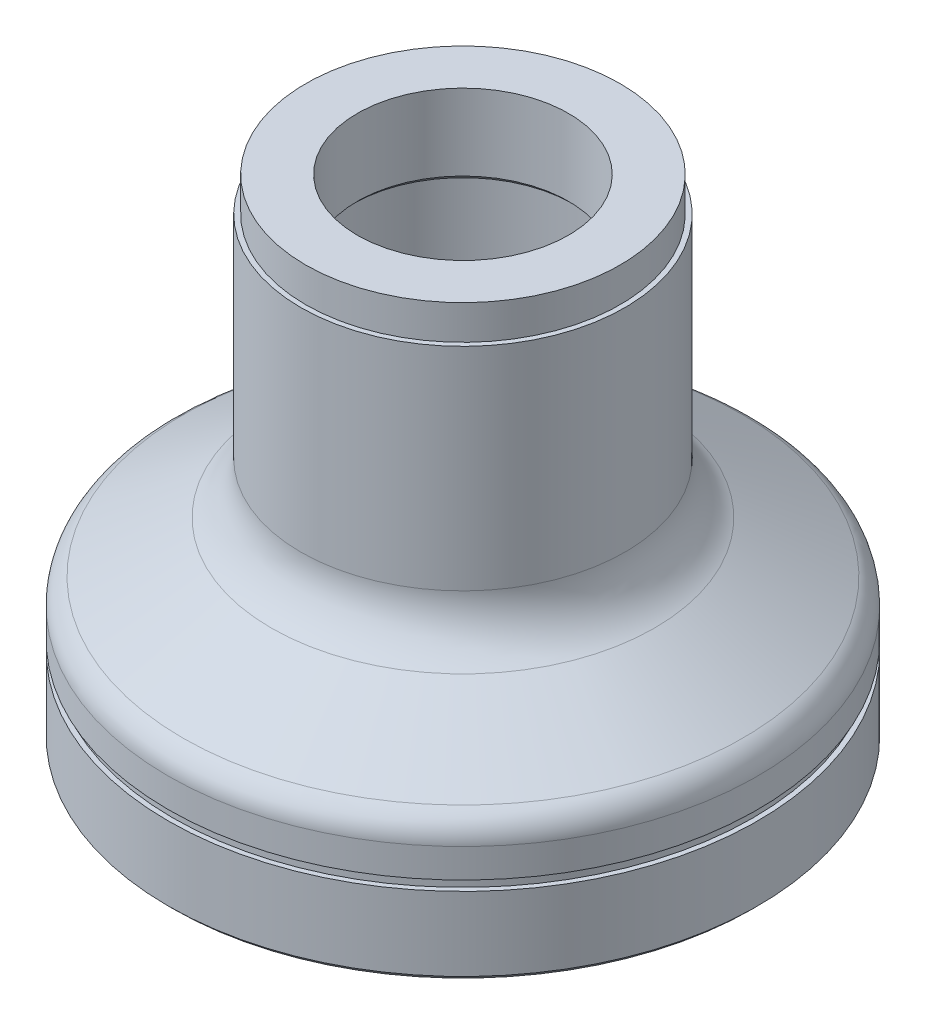
from build123d import *


with BuildPart() as part:
    # Esquisse1 → Révolution1 (revolve)
    with BuildSketch(Plane.XY, mode=Mode.PRIVATE) as r_volution1_sk:
        with BuildLine():
            Line((33, 94.535053287), (33, 51.422205102))
            ThreePointArc((33, 51.422205102), (34.607695155, 45.422205102), (39, 41.029900256))
            Line((39, 41.029900256), (57, 30.637595411))
            ThreePointArc((57, 30.637595411), (59.196152423, 28.441442988), (60, 25.441442988))
            Line((60, 25.441442988), (60, 19.535053287))
            Line((60, 19.535053287), (59, 19.535053287))
            Line((59, 19.535053287), (59, 17.535053287))
            Line((59, 17.535053287), (60, 17.535053287))
            Line((60, 17.535053287), (60, 2.535053287))
            Line((60, 2.535053287), (59, 1.535053287))
            Line((59, 1.535053287), (57, 1.535053287))
            Line((57, 1.535053287), (57, 6.535053287))
            Line((57, 6.535053287), (49, 6.535053287))
            Line((49, 6.535053287), (49, 24.535053287))
            Line((49, 24.535053287), (55, 24.535053287))
            Line((55, 24.535053287), (55, 27.035053287))
            Line((55, 27.035053287), (50, 27.035053287))
            Line((50, 27.035053287), (50, 29.035053287))
            Line((50, 29.035053287), (49.01666888, 29.035053287))
            ThreePointArc((49.01666888, 29.035053287), (48.71714205, 29.953920875), (48.021719707, 30.625055533))
            Line((48.021719707, 30.625055533), (38.852533252, 35.9188878))
            ThreePointArc((38.852533252, 35.9188878), (37.136356036, 36.054212208), (35.950790389, 34.806009088))
            Line((35.950790389, 34.806009088), (35, 31.885724321))
            Line((35, 31.885724321), (28, 31.885724321))
            Line((28, 31.885724321), (27, 32.885724321))
            Line((27, 32.885724321), (27, 85.035053287))
            Line((27, 85.035053287), (22.5, 85.035053287))
            Line((22.5, 85.035053287), (21.5, 86.035053287))
            Line((21.5, 86.035053287), (21.5, 101.535053287))
            Line((21.5, 101.535053287), (32, 101.535053287))
            Line((32, 101.535053287), (32, 94.535053287))
            Line((32, 94.535053287), (33, 94.535053287))
        make_face()
    revolve(r_volution1_sk.sketch.rotate(Axis((0, 108.46930196, 0), (0, -1, 0)), 90), axis=Axis((0, 108.46930196, 0), (0, -1, 0)))  # turned: the seam where the file's is


solid = part.part
